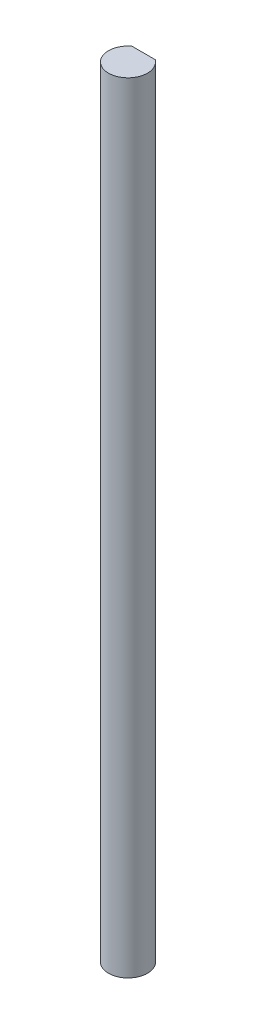
from build123d import *

# Parameters (mm, degrees)
BOSS_EXTRUDE1_DEPTH = 127


with BuildPart() as part:
    # Sketch1 → Boss-Extrude1 (new body)
    with BuildSketch(Plane(origin=(0, 0, 0), x_dir=(1, 0, 0), z_dir=(0, 1, 0))):
        with BuildLine():
            Line((-1.905, 2.54), (1.905, 2.54))
            ThreePointArc((1.905, 2.54), (0, -3.175), (-1.905, 2.54))
        make_face()
    extrude(amount=BOSS_EXTRUDE1_DEPTH)


solid = part.part
